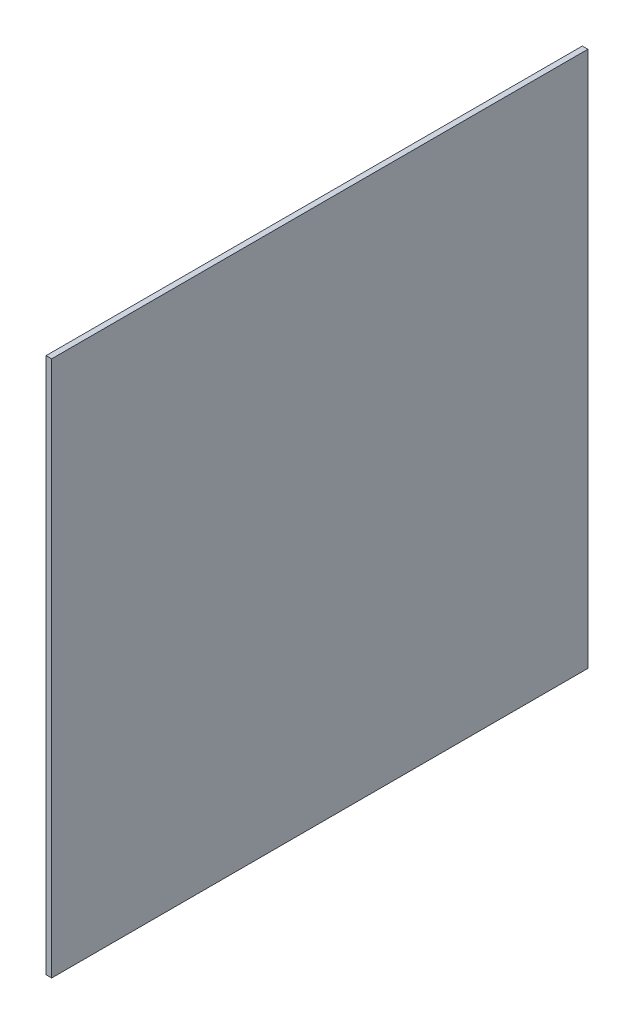
from build123d import *

# Parameters (mm, degrees)
SKETCH1_W           = 304.8
SKETCH1_H           = 304.8
BOSS_EXTRUDE1_DEPTH = 3.175


with BuildPart() as part:
    # Sketch1 → Boss-Extrude1 (new body)
    with BuildSketch(Plane(origin=(0, 0, 0), x_dir=(0, 0, -1), z_dir=(1, 0, 0))):
        Rectangle(SKETCH1_W, SKETCH1_H)
    extrude(amount=BOSS_EXTRUDE1_DEPTH)


solid = part.part
